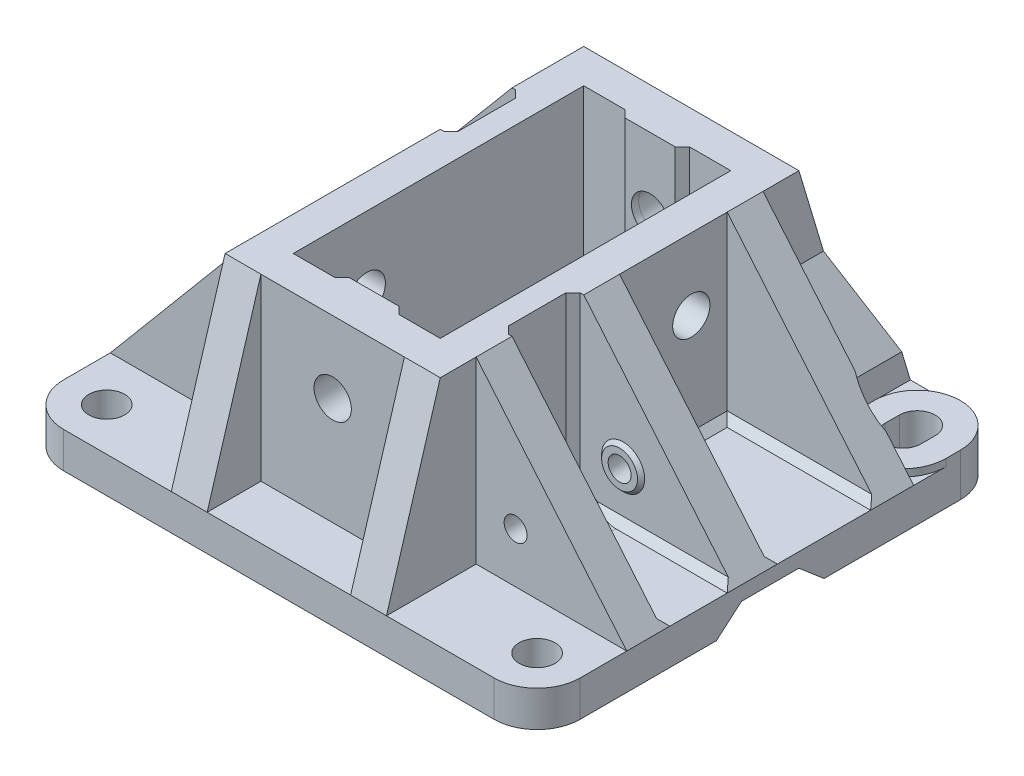
from build123d import *

# Parameters (mm, degrees)
SKETCH1_W               = 72
SKETCH1_H               = 65
BOSS_EXTRUDE1_DEPTH     = 5
SKETCH2_W               = 30
SKETCH2_H               = 50
BOSS_EXTRUDE2_DEPTH     = 25
SKETCH4_W               = 20.5
SKETCH4_H               = 40.5
CUT_EXTRUDE1_DEPTH      = 25
BOSS_EXTRUDE3_DEPTH     = 5
MIRROR2_COPY_1_DEPTH    = 5
BOSS_EXTRUDE4_START     = -5
BOSS_EXTRUDE4_DEPTH     = 5
BOSS_EXTRUDE5_DEPTH     = 5
MIRROR4_START           = -5
MIRROR4_COPY_1_DEPTH    = 5
BOSS_EXTRUDE6_DEPTH     = 5
FILLET1_R               = 6
CUT_EXTRUDE3_DEPTH      = 75
SKETCH11_R              = 2.5
CUT_EXTRUDE4_DEPTH      = 5
SKETCH12_R              = 1.6
CUT_EXTRUDE5_DEPTH      = 5
SKETCH13_R              = 2.602149029
CUT_EXTRUDE6_DEPTH      = 7
SKETCH14_W              = 7
SKETCH14_H              = 25
BOSS_EXTRUDE7_DEPTH     = 1
BOSS_EXTRUDE8_DEPTH     = 25
MIRROR8_COPY_1_DEPTH    = 25
SKETCH16_R              = 2.6
CUT_EXTRUDE7_DEPTH      = 65
CUT_EXTRUDE8_DEPTH      = 102.533245787
CUT_EXTRUDE8_DEPTH_BACK = 25
FILLET5_R               = 7
CUT_EXTRUDE9_DEPTH      = 25
FILLET6_R               = 7
BOSS_EXTRUDE10_DEPTH    = 25
BOSS_EXTRUDE11_DEPTH    = 25
BOSS_EXTRUDE12_DEPTH    = 15
BOSS_EXTRUDE13_DEPTH    = 25
BOSS_EXTRUDE14_DEPTH    = 25
SKETCH28_W              = 39.163365543
SKETCH28_H              = 8.307401159
CUT_EXTRUDE10_DEPTH     = 5
BOSS_EXTRUDE15_DEPTH    = 25
BOSS_EXTRUDE16_DEPTH    = 15
BOSS_EXTRUDE17_DEPTH    = 25
SKETCH32_R              = 3
BOSS_EXTRUDE18_DEPTH    = 0.5
BOSS_EXTRUDE18_TAPER    = 45
SKETCH33_R              = 1.6
CUT_EXTRUDE11_DEPTH     = 20.5
SKETCH34_R              = 3
BOSS_EXTRUDE19_DEPTH    = 0.5
BOSS_EXTRUDE19_TAPER    = 45
SKETCH35_R              = 1.6
CUT_EXTRUDE12_DEPTH     = 10.5
SKETCH37_R              = 3
BOSS_EXTRUDE20_DEPTH    = 0.5
BOSS_EXTRUDE20_TAPER    = 45
SKETCH38_R              = 3
BOSS_EXTRUDE21_DEPTH    = 0.5
BOSS_EXTRUDE21_TAPER    = 45
SKETCH36_R              = 1.6
CUT_EXTRUDE13_DEPTH     = 20.5
SKETCH40_R              = 2.6
CUT_EXTRUDE14_DEPTH     = 10
SKETCH41_R              = 2.6
CUT_EXTRUDE15_DEPTH     = 10
BOSS_EXTRUDE22_DEPTH    = 1
CUT_EXTRUDE17_DEPTH     = 11
CUT_EXTRUDE18_DEPTH     = 10
BOSS_EXTRUDE23_DEPTH    = 12.5
SKETCH50_R              = 2
CUT_EXTRUDE20_DEPTH     = 12.5
SKETCH49_W              = 13.457304279
SKETCH49_H              = 22.246433757
CUT_EXTRUDE21_DEPTH     = 12.5
CUT_EXTRUDE22_DEPTH     = 10


with BuildPart() as part:
    # Sketch1 → Boss-Extrude1 (new body)
    with BuildSketch(Plane(origin=(0, 0, 0), x_dir=(1, 0, 0), z_dir=(0, 1, 0))):
        with Locations((36, 32.5)):
            Rectangle(SKETCH1_W, SKETCH1_H)
    extrude(amount=BOSS_EXTRUDE1_DEPTH)

    # Sketch2 → Boss-Extrude2 (add)
    with BuildSketch(Plane(origin=(0, 5, 0), x_dir=(1, 0, 0), z_dir=(0, 1, 0))):
        with Locations((36, 32.5)):
            Rectangle(SKETCH2_W, SKETCH2_H)
    extrude(amount=BOSS_EXTRUDE2_DEPTH)

    # Sketch4 → Cut-Extrude1 (cut)
    with BuildSketch(Plane(origin=(0, 30, 0), x_dir=(1, 0, 0), z_dir=(0, 1, 0))):
        with Locations((36, 32.5)):
            Rectangle(SKETCH4_W, SKETCH4_H)
    extrude(amount=-CUT_EXTRUDE1_DEPTH, mode=Mode.SUBTRACT)

    # Sketch5 → Boss-Extrude3 (add)
    with BuildSketch(Plane(origin=(51, 0, 0), x_dir=(0, 0, -1), z_dir=(1, 0, 0))):
        Polygon((57.5, 30), (65, 5), (57.5, 5), align=None)
    boss_extrude3 = extrude(amount=-BOSS_EXTRUDE3_DEPTH)

    # Mirror1: Boss-Extrude3 across plane
    add(boss_extrude3.mirror(Plane(origin=(36, 0, 0), x_dir=(0, 0, 1), z_dir=(1, 0, 0))))

    # Mirror2: Boss-Extrude3 across plane
    add(boss_extrude3.mirror(Plane.XY.offset(-32.5)))

    # Mirror2 copy 1 sketch → Mirror2 copy 1 (add)
    with BuildSketch(Plane(origin=(21, 0, -65), x_dir=(0, 0, 1), z_dir=(-1, 0, 0))):
        Polygon((57.5, 30), (65, 5), (57.5, 5), align=None)
    extrude(amount=-MIRROR2_COPY_1_DEPTH)

    # Sketch6 → Boss-Extrude4 (add)
    with BuildSketch(Plane.XY.offset(-7.5).offset(BOSS_EXTRUDE4_START)):
        Polygon((51, 30), (72, 5), (51, 5), align=None)
    boss_extrude4 = extrude(amount=-BOSS_EXTRUDE4_DEPTH)

    # Mirror3: Boss-Extrude4 across plane
    add(boss_extrude4.mirror(Plane.XY.offset(-32.5)))

    # Sketch7 → Boss-Extrude5 (add)
    with BuildSketch(Plane.XY.offset(-32.5)):
        Polygon((51, 30), (72, 5), (51, 5), align=None)
    extrude(amount=BOSS_EXTRUDE5_DEPTH)

    # Mirror4: Boss-Extrude4 across plane
    add(boss_extrude4.mirror(Plane(origin=(36, 0, 0), x_dir=(0, 0, 1), z_dir=(1, 0, 0))))

    # Mirror4 copy 1 sketch → Mirror4 copy 1 (add)
    with BuildSketch(Plane(origin=(72, 0, -57.5), x_dir=(-1, 0, 0), z_dir=(0, 0, -1)).offset(MIRROR4_START)):
        Polygon((51, 30), (72, 5), (51, 5), align=None)
    extrude(amount=-MIRROR4_COPY_1_DEPTH)

    # Sketch8 → Boss-Extrude6 (add)
    with BuildSketch(Plane.XY.offset(-32.5)):
        Polygon((21, 30), (0, 5), (21, 5), align=None)
    extrude(amount=-BOSS_EXTRUDE6_DEPTH)

    # Fillet1
    fillet1_edges = [part.edges().sort_by_distance(p)[0] for p in [
        (0, 2.5, 0),
        (0, 2.5, -65),
        (72, 2.5, -65),
        (72, 2.5, 0),
    ]]
    fillet(fillet1_edges, radius=FILLET1_R)

    # Sketch10 → Cut-Extrude3 (cut)
    with BuildSketch(Plane(origin=(72, 0, 0), x_dir=(0, 0, -1), z_dir=(1, 0, 0))):
        Polygon((40, 0), (36.5, 3), (32.5, 3), (28.5, 3), (25, 0), align=None)
    extrude(amount=-CUT_EXTRUDE3_DEPTH, mode=Mode.SUBTRACT)

    # Sketch11 → Cut-Extrude4 (cut)
    with BuildSketch(Plane(origin=(0, 5, 0), x_dir=(1, 0, 0), z_dir=(0, 1, 0))):
        with Locations(Location((66, 6, 0), (0, 0, 270))):
            Circle(SKETCH11_R)
    cut_extrude4 = extrude(amount=-CUT_EXTRUDE4_DEPTH, mode=Mode.SUBTRACT)

    # Mirror6: Cut-Extrude4 across plane
    add(cut_extrude4.mirror(Plane(origin=(36, 0, 0), x_dir=(0, 0, 1), z_dir=(1, 0, 0))), mode=Mode.SUBTRACT)

    # Sketch12 → Cut-Extrude5 (cut)
    with BuildSketch(Plane.XY.offset(-12.5)):
        with Locations((56.5, 12)):
            Circle(SKETCH12_R)
    extrude(amount=-CUT_EXTRUDE5_DEPTH, mode=Mode.SUBTRACT)

    # Sketch13 → Cut-Extrude6 (cut)
    with BuildSketch(Plane.XY.offset(-7.5)):
        with Locations((36, 20)):
            Circle(SKETCH13_R)
    cut_extrude6 = extrude(amount=-CUT_EXTRUDE6_DEPTH, mode=Mode.SUBTRACT)

    # Sketch14 → Boss-Extrude7 (add)
    with BuildSketch(Plane(origin=(0, 0, -12.25), x_dir=(-1, 0, 0), z_dir=(0, 0, -1))):
        with Locations((-36, 17.5)):
            Rectangle(SKETCH14_W, SKETCH14_H)
    boss_extrude7 = extrude(amount=BOSS_EXTRUDE7_DEPTH)

    # Sketch15 → Boss-Extrude8 (add)
    with BuildSketch(Plane(origin=(0, 30, 0), x_dir=(1, 0, 0), z_dir=(0, 1, 0))):
        Polygon((39.5, 13.25), (40.5, 12.25), (39.5, 12.25), align=None)
    boss_extrude8 = extrude(amount=-BOSS_EXTRUDE8_DEPTH)

    # Mirror7: Boss-Extrude8 across plane
    add(boss_extrude8.mirror(Plane(origin=(36, 0, 0), x_dir=(0, 0, 1), z_dir=(1, 0, 0))))

    # Mirror8: Cut-Extrude6, Boss-Extrude7, Boss-Extrude8 across plane
    add(cut_extrude6.mirror(Plane.XY.offset(-32.5)), mode=Mode.SUBTRACT)
    add(boss_extrude7.mirror(Plane.XY.offset(-32.5)))
    add(boss_extrude8.mirror(Plane.XY.offset(-32.5)))

    # Mirror8 copy 1 sketch → Mirror8 copy 1 (add)
    with BuildSketch(Plane(origin=(72, 30, -65), x_dir=(-1, 0, 0), z_dir=(0, 1, 0))):
        Polygon((39.5, 13.25), (40.5, 12.25), (39.5, 12.25), align=None)
    extrude(amount=-MIRROR8_COPY_1_DEPTH)

    # Sketch16 → Cut-Extrude7 (cut)
    with BuildSketch(Plane.XY.offset(-12.25)):
        with Locations((36, 20)):
            Circle(SKETCH16_R)
    extrude(amount=-CUT_EXTRUDE7_DEPTH, mode=Mode.SUBTRACT)

    # Sketch21 → Cut-Extrude8 (cut, two sides)
    with BuildSketch(Plane(origin=(0, 30, 0), x_dir=(1, 0, 0), z_dir=(0, 1, 0))) as cut_extrude8_sk:
        Polygon((21.5, 47.5), (22.5, 46.5), (22.5, 38.5), (21.5, 37.5), (21, 37.5), (21, 47.5), align=None)
    extrude(amount=CUT_EXTRUDE8_DEPTH, mode=Mode.SUBTRACT)
    extrude(cut_extrude8_sk.sketch, amount=-CUT_EXTRUDE8_DEPTH_BACK, mode=Mode.SUBTRACT)

    # Fillet5
    fillet5_edges = [part.edges().sort_by_distance(p)[0] for p in [
        (22.5, 5, -42.5),
    ]]
    fillet(fillet5_edges, radius=FILLET5_R)

    # Sketch22 → Cut-Extrude9 (cut)
    with BuildSketch(Plane(origin=(0, 30, 0), x_dir=(1, 0, 0), z_dir=(0, 1, 0))):
        Polygon((51, 17.5), (50.49936831, 17.5), (49.49936831, 18.5), (49.49936831, 26.5), (50.49936831, 27.5), (51, 27.5), align=None)
    extrude(amount=-CUT_EXTRUDE9_DEPTH, mode=Mode.SUBTRACT)

    # Fillet6
    fillet6_edges = [part.edges().sort_by_distance(p)[0] for p in [
        (49.49936831, 5, -22.5),
    ]]
    fillet(fillet6_edges, radius=FILLET6_R)

    # Sketch23 → Boss-Extrude10 (add)
    with BuildSketch(Plane(origin=(72, 0, 0), x_dir=(0, 0, -1), z_dir=(1, 0, 0))):
        Polygon((17.5, 5), (17.5, 5.998380503), (18.502323497, 5), align=None)
    extrude(amount=-BOSS_EXTRUDE10_DEPTH)

    # Sketch24 → Boss-Extrude11 (add)
    with BuildSketch(Plane(origin=(72, 0, 0), x_dir=(0, 0, -1), z_dir=(1, 0, 0))):
        Polygon((27.5, 5), (27.5, 6), (26.5, 5), align=None)
    extrude(amount=-BOSS_EXTRUDE11_DEPTH)

    # Sketch25 → Boss-Extrude12 (add)
    with BuildSketch(Plane(origin=(0, 0, -32.5), x_dir=(-1, 0, 0), z_dir=(0, 0, -1))):
        Polygon((-51, 5), (-51, 5.997769202), (-52, 5), align=None)
    extrude(amount=BOSS_EXTRUDE12_DEPTH)

    # Sketch26 → Boss-Extrude13 (add)
    with BuildSketch(Plane(origin=(72, 0, 0), x_dir=(0, 0, -1), z_dir=(1, 0, 0))):
        Polygon((32.5, 5), (32.5, 5.997218908), (33.5, 5), align=None)
    extrude(amount=-BOSS_EXTRUDE13_DEPTH)

    # Sketch27 → Boss-Extrude14 (add)
    with BuildSketch(Plane(origin=(72, 0, 0), x_dir=(0, 0, -1), z_dir=(1, 0, 0))):
        Polygon((47.5, 5), (47.5, 6), (46.5, 5), align=None)
    extrude(amount=-BOSS_EXTRUDE14_DEPTH)

    # Sketch28 → Cut-Extrude10 (cut)
    with BuildSketch(Plane(origin=(44.676360225, 37.528142589, 0), x_dir=(0, 0, -1), z_dir=(0.7657048647896111, 0.6431920864232733, 0))):
        with Locations((30.993839272, -39.424779611)):
            Rectangle(SKETCH28_W, SKETCH28_H)
    cut_extrude10 = extrude(amount=CUT_EXTRUDE10_DEPTH, mode=Mode.SUBTRACT)

    # Sketch29 → Boss-Extrude15 (add)
    with BuildSketch(Plane.ZY):
        Polygon((-47.5, 5), (-47.5, 6), (-46.5, 5), align=None)
        Polygon((-37.5, 5), (-37.5, 6), (-38.5, 5), align=None)
    extrude(amount=-BOSS_EXTRUDE15_DEPTH)

    # Sketch30 → Boss-Extrude16 (add)
    with BuildSketch(Plane.XY.offset(-32.5)):
        Polygon((21, 5), (20, 5), (21, 6), align=None)
    extrude(amount=BOSS_EXTRUDE16_DEPTH)

    # Sketch31 → Boss-Extrude17 (add)
    with BuildSketch(Plane.ZY):
        Polygon((-32.5, 5), (-32.5, 6), (-31.5, 5), align=None)
        Polygon((-17.5, 5), (-17.5, 6.000584877), (-18.500584877, 5), align=None)
    extrude(amount=-BOSS_EXTRUDE17_DEPTH)

    # Mirror10: Cut-Extrude10 across plane
    add(cut_extrude10.mirror(Plane(origin=(36, 0, 0), x_dir=(0, 0, 1), z_dir=(1, 0, 0))), mode=Mode.SUBTRACT)

    # Sketch32 → Boss-Extrude18 (add)
    with BuildSketch(Plane(origin=(0, 0, -17.5), x_dir=(-1, 0, 0), z_dir=(0, 0, -1))):
        with Locations((-56.5, 12)):
            Circle(SKETCH32_R)
    extrude(amount=BOSS_EXTRUDE18_DEPTH, taper=BOSS_EXTRUDE18_TAPER)

    # Sketch33 → Cut-Extrude11 (cut)
    with BuildSketch(Plane.XY.offset(-12.5)):
        with Locations((56.5, 12)):
            Circle(SKETCH33_R)
    extrude(amount=-CUT_EXTRUDE11_DEPTH, mode=Mode.SUBTRACT)

    # Sketch34 → Boss-Extrude19 (add)
    with BuildSketch(Plane.XY.offset(-27.5)):
        with Locations((56.5, 12)):
            Circle(SKETCH34_R)
    extrude(amount=BOSS_EXTRUDE19_DEPTH, taper=BOSS_EXTRUDE19_TAPER)

    # Sketch35 → Cut-Extrude12 (cut)
    with BuildSketch(Plane(origin=(0, 0, -32.5), x_dir=(-1, 0, 0), z_dir=(0, 0, -1))):
        with Locations(Location((-56.5, 12, 0), (0, 0, 180))):
            Circle(SKETCH35_R)
    extrude(amount=-CUT_EXTRUDE12_DEPTH, mode=Mode.SUBTRACT)

    # Sketch37 → Boss-Extrude20 (add)
    with BuildSketch(Plane.XY.offset(-47.5)):
        with Locations((15.5, 12)):
            Circle(SKETCH37_R)
    extrude(amount=BOSS_EXTRUDE20_DEPTH, taper=BOSS_EXTRUDE20_TAPER)

    # Sketch38 → Boss-Extrude21 (add)
    with BuildSketch(Plane(origin=(0, 0, -37.5), x_dir=(-1, 0, 0), z_dir=(0, 0, -1))):
        with Locations((-15.5, 12)):
            Circle(SKETCH38_R)
    extrude(amount=BOSS_EXTRUDE21_DEPTH, taper=BOSS_EXTRUDE21_TAPER)

    # Sketch36 → Cut-Extrude13 (cut)
    with BuildSketch(Plane(origin=(0, 0, -52.5), x_dir=(-1, 0, 0), z_dir=(0, 0, -1))):
        with Locations((-15.5, 12)):
            Circle(SKETCH36_R)
    extrude(amount=-CUT_EXTRUDE13_DEPTH, mode=Mode.SUBTRACT)

    # Sketch40 → Cut-Extrude14 (cut)
    with BuildSketch(Plane.ZY.offset(-21)):
        with Locations((-22.5, 20)):
            Circle(SKETCH40_R)
    extrude(amount=-CUT_EXTRUDE14_DEPTH, mode=Mode.SUBTRACT)

    # Sketch41 → Cut-Extrude15 (cut)
    with BuildSketch(Plane(origin=(51, 0, 0), x_dir=(0, 0, -1), z_dir=(1, 0, 0))):
        with Locations((42.5, 20)):
            Circle(SKETCH41_R)
    extrude(amount=-CUT_EXTRUDE15_DEPTH, mode=Mode.SUBTRACT)

    # Sketch9 → Boss-Extrude22 (add)
    with BuildSketch(Plane(origin=(0, 5, 0), x_dir=(1, 0, 0), z_dir=(0, 1, 0))):
        with BuildLine():
            Line((60, 59), (60, 57))
            ThreePointArc((60, 57), (66, 51), (72, 57))
            Line((72, 57), (72, 59))
            ThreePointArc((72, 59), (66, 65), (60, 59))
        make_face()
        with BuildLine():
            Line((63.5, 59), (63.5, 57))
            ThreePointArc((63.5, 57), (66, 54.5), (68.5, 57))
            Line((68.5, 57), (68.5, 59))
            ThreePointArc((68.5, 59), (66, 61.5), (63.5, 59))
        make_face(mode=Mode.SUBTRACT)
    boss_extrude22 = extrude(amount=BOSS_EXTRUDE22_DEPTH)

    # Sketch45 → Cut-Extrude17 (cut)
    with BuildSketch(Plane(origin=(0, 6, 0), x_dir=(1, 0, 0), z_dir=(0, 1, 0))):
        with BuildLine():
            Line((68.179449472, 52.5), (63.80757516, 52.506307385))
            ThreePointArc((63.80757516, 52.506307385), (65.992786414, 52.000005204), (68.179449472, 52.5))
        make_face()
    cut_extrude17 = extrude(amount=CUT_EXTRUDE17_DEPTH, mode=Mode.SUBTRACT)

    # Sketch47 → Cut-Extrude18 (cut)
    with BuildSketch(Plane(origin=(0, 5, 0), x_dir=(1, 0, 0), z_dir=(0, 1, 0))):
        with BuildLine():
            Line((68.5, 59), (68.5, 57))
            ThreePointArc((68.5, 57), (66, 54.5), (63.5, 57))
            Line((63.5, 57), (63.5, 59))
            ThreePointArc((63.5, 59), (66, 61.5), (68.5, 59))
        make_face()
    extrude(amount=-CUT_EXTRUDE18_DEPTH, mode=Mode.SUBTRACT)

    # Mirror12: Boss-Extrude22, Cut-Extrude17 across plane
    add(boss_extrude22.mirror(Plane(origin=(36, 0, 0), x_dir=(0, 0, 1), z_dir=(1, 0, 0))))
    add(cut_extrude17.mirror(Plane(origin=(36, 0, 0), x_dir=(0, 0, 1), z_dir=(1, 0, 0))), mode=Mode.SUBTRACT)

    # Sketch48 → Boss-Extrude23 (add)
    with BuildSketch(Plane(origin=(0, 0, -52.5), x_dir=(-1, 0, 0), z_dir=(0, 0, -1))):
        Polygon((-59.034845121, 5), (-59.034845121, 9), (-51, 18.575555539), (-51, 5), align=None)
    extrude(amount=BOSS_EXTRUDE23_DEPTH)

    # Sketch50 → Cut-Extrude20 (cut)
    with BuildSketch(Plane(origin=(0, 0, -65), x_dir=(-1, 0, 0), z_dir=(0, 0, -1))):
        with Locations((-52.534845121, 7)):
            Circle(SKETCH50_R)
    extrude(amount=-CUT_EXTRUDE20_DEPTH, mode=Mode.SUBTRACT)

    # Sketch49 → Cut-Extrude21 (cut)
    with BuildSketch(Plane(origin=(0, 18.302752294, -61.009174312), x_dir=(-1, 0, 0), z_dir=(0, 0.28734788556634494, -0.9578262852211515))):
        with Locations((-55.129520737, -3.512971616)):
            Rectangle(SKETCH49_W, SKETCH49_H)
    extrude(amount=CUT_EXTRUDE21_DEPTH, mode=Mode.SUBTRACT)

    # Mirror13: Boss-Extrude22 across plane
    add(boss_extrude22.mirror(Plane(origin=(36, 0, 0), x_dir=(0, 0, 1), z_dir=(1, 0, 0))))

    # Sketch51 → Cut-Extrude22 (cut)
    with BuildSketch(Plane(origin=(0, 5, 0), x_dir=(1, 0, 0), z_dir=(0, 1, 0))):
        with BuildLine():
            Line((8.5, 59), (8.5, 57))
            ThreePointArc((8.5, 57), (6, 54.5), (3.5, 57))
            Line((3.5, 57), (3.5, 59))
            ThreePointArc((3.5, 59), (6, 61.5), (8.5, 59))
        make_face()
    extrude(amount=-CUT_EXTRUDE22_DEPTH, mode=Mode.SUBTRACT)


solid = part.part
